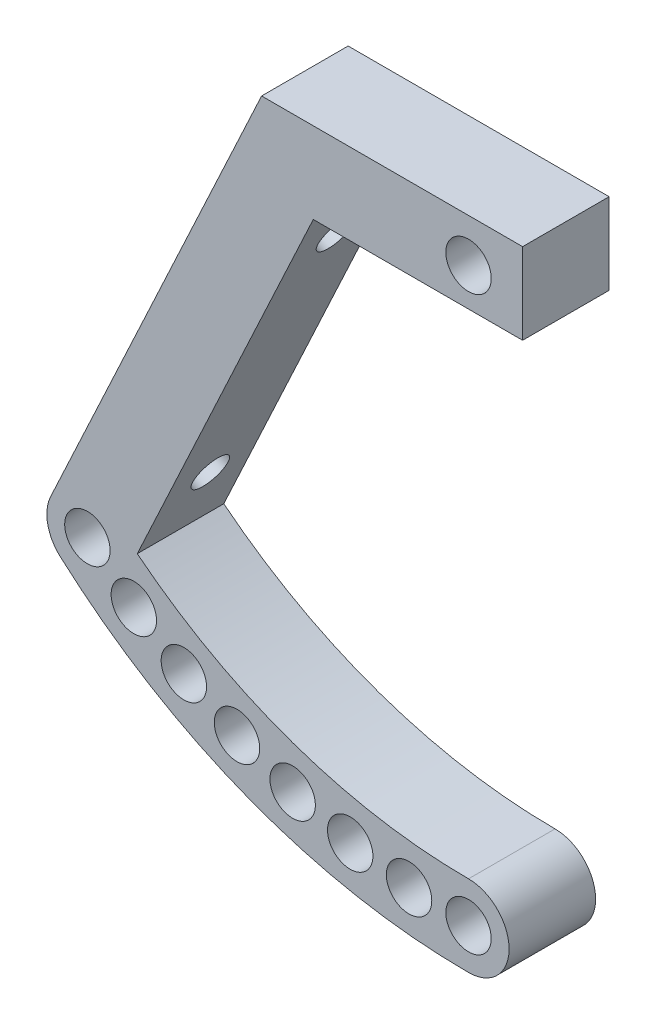
from build123d import *

# Parameters (mm, degrees)
SKETCH1_R           = 2.1
BOSS_EXTRUDE1_DEPTH = 8
CUT_EXTRUDE1_REACH  = 49.49
SKETCH2_R           = 1.65


with BuildPart() as part:
    # Sketch1 → Boss-Extrude1 (new body)
    with BuildSketch(Plane.XY):
        Polygon((-14.353967242, 72.5), (5, 72.5), (5, 80), (-19.131994198, 80), (-12.334685795, 76.830363037), align=None)
        with Locations((0, 76)):
            Circle(SKETCH1_R, mode=Mode.SUBTRACT)
        Polygon((-19.131994198, 72.5), (-14.353967242, 72.5), (-12.334685795, 76.830363037), (-19.131994198, 80), align=None)
        with BuildLine():
            Line((-30.628506806, 37.599137276), (-14.353967242, 72.5))
            Line((-14.353967242, 72.5), (-19.131994198, 72.5))
            Line((-19.131994198, 72.5), (-19.131994198, 80))
            Line((-19.131994198, 80), (-38.637128487, 38.171104532))
            ThreePointArc((-38.637128487, 38.171104532), (-35.992554118, 40.259685439), (-32.739034841, 39.381872183))
            ThreePointArc((-32.739034841, 39.381872183), (-31.696306875, 38.475663662), (-30.628506806, 37.599137276))
        make_face()
        with BuildLine():
            Line((-31.819822815, 35.044351851), (-30.628506806, 37.599137276))
            ThreePointArc((-30.628506806, 37.599137276), (-31.696306875, 38.475663662), (-32.739034841, 39.381872183))
            ThreePointArc((-32.739034841, 39.381872183), (-35.992554118, 40.259685439), (-38.637128487, 38.171104532))
            ThreePointArc((-38.637128487, 38.171104532), (-38.911873793, 35.832206175), (-37.737913805, 33.790699757))
            ThreePointArc((-37.737913805, 33.790699757), (-37.315296786, 33.416625413), (-36.888971991, 33.046782299))
            Line((-36.888971991, 33.046782299), (-33.490317789, 31.461963818))
            Line((-33.490317789, 31.461963818), (-32.97126033, 32.575086132))
            ThreePointArc((-32.97126033, 32.575086132), (-32.850330683, 34.021790637), (-31.819822815, 35.044351851))
        make_face()
        with Locations((-35.238474323, 36.58628597)):
            Circle(SKETCH1_R, mode=Mode.SUBTRACT)
        with BuildLine():
            ThreePointArc((0, 26.880434783), (-16.224950018, 29.637486219), (-30.628506806, 37.599137276))
            Line((-30.628506806, 37.599137276), (-31.819822815, 35.044351851))
            ThreePointArc((-31.819822815, 35.044351851), (-29.811908313, 34.901033754), (-28.847084331, 33.134292287))
            ThreePointArc((-28.847084331, 33.134292287), (-30.664922673, 31.053334623), (-32.97126033, 32.575086132))
            Line((-32.97126033, 32.575086132), (-33.490317789, 31.461963818))
            Line((-33.490317789, 31.461963818), (-36.888971991, 33.046782299))
            ThreePointArc((-36.888971991, 33.046782299), (-19.669553306, 22.906838122), (0, 19.380434783))
            ThreePointArc((0, 19.380434783), (3.75, 23.130434783), (0, 26.880434783))
        make_face()
        with Locations((-26.319869018, 30.147460036)):
            Circle(SKETCH1_R, mode=Mode.SUBTRACT)
        with Locations((-21.407041065, 27.658201118)):
            Circle(SKETCH1_R, mode=Mode.SUBTRACT)
        with Locations((-16.261912507, 25.693527972)):
            Circle(SKETCH1_R, mode=Mode.SUBTRACT)
        with Locations((-10.940316211, 24.274760441)):
            Circle(SKETCH1_R, mode=Mode.SUBTRACT)
        with Locations((-5.5, 23.417294418)):
            Circle(SKETCH1_R, mode=Mode.SUBTRACT)
        with Locations((0, 23.130434783)):
            Circle(SKETCH1_R, mode=Mode.SUBTRACT)
    extrude(amount=BOSS_EXTRUDE1_DEPTH)

    # Sketch2 → Cut-Extrude1 (cut, up to next)
    with BuildSketch(Plane(origin=(-46.356679233, 21.616474533, 0), x_dir=(0, 0, 1), z_dir=(-0.906307787, 0.422618262, 0)), mode=Mode.PRIVATE) as cut_extrude1_sk1:
        with Locations((4, 55.04255297)):
            Circle(SKETCH2_R)
    cut_extrude1_tool1 = extrude(cut_extrude1_sk1.sketch, amount=-CUT_EXTRUDE1_REACH, mode=Mode.PRIVATE) & part.part
    add(cut_extrude1_tool1.solids().sort_by_distance((-23.094691, 71.501969, 4))[0], mode=Mode.SUBTRACT)
    # Sketch2 → Cut-Extrude1 (cut, up to next)
    with BuildSketch(Plane(origin=(-46.356679233, 21.616474533, 0), x_dir=(0, 0, 1), z_dir=(-0.906307787, 0.422618262, 0)), mode=Mode.PRIVATE) as cut_extrude1_sk2:
        with Locations((4, 27.64255297)):
            Circle(SKETCH2_R)
    cut_extrude1_tool2 = extrude(cut_extrude1_sk2.sketch, amount=-CUT_EXTRUDE1_REACH, mode=Mode.PRIVATE) & part.part
    add(cut_extrude1_tool2.solids().sort_by_distance((-34.674432, 46.669136, 4))[0], mode=Mode.SUBTRACT)


solid = part.part
